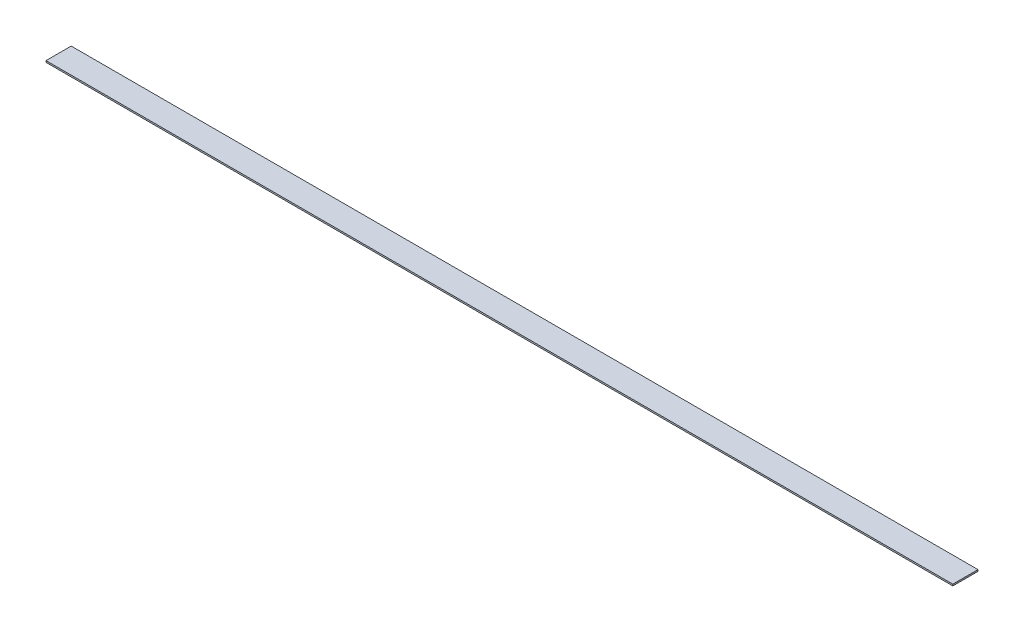
from build123d import *

# Parameters (mm, degrees)
SKETCH1_W           = 914.4
SKETCH1_H           = 25.4
BOSS_EXTRUDE1_DEPTH = 1.5875


with BuildPart() as part:
    # Sketch1 → Boss-Extrude1 (new body)
    with BuildSketch(Plane(origin=(0, 0, 0), x_dir=(1, 0, 0), z_dir=(0, 1, 0))):
        with Locations((457.2, 12.7)):
            Rectangle(SKETCH1_W, SKETCH1_H)
    extrude(amount=BOSS_EXTRUDE1_DEPTH)


solid = part.part
